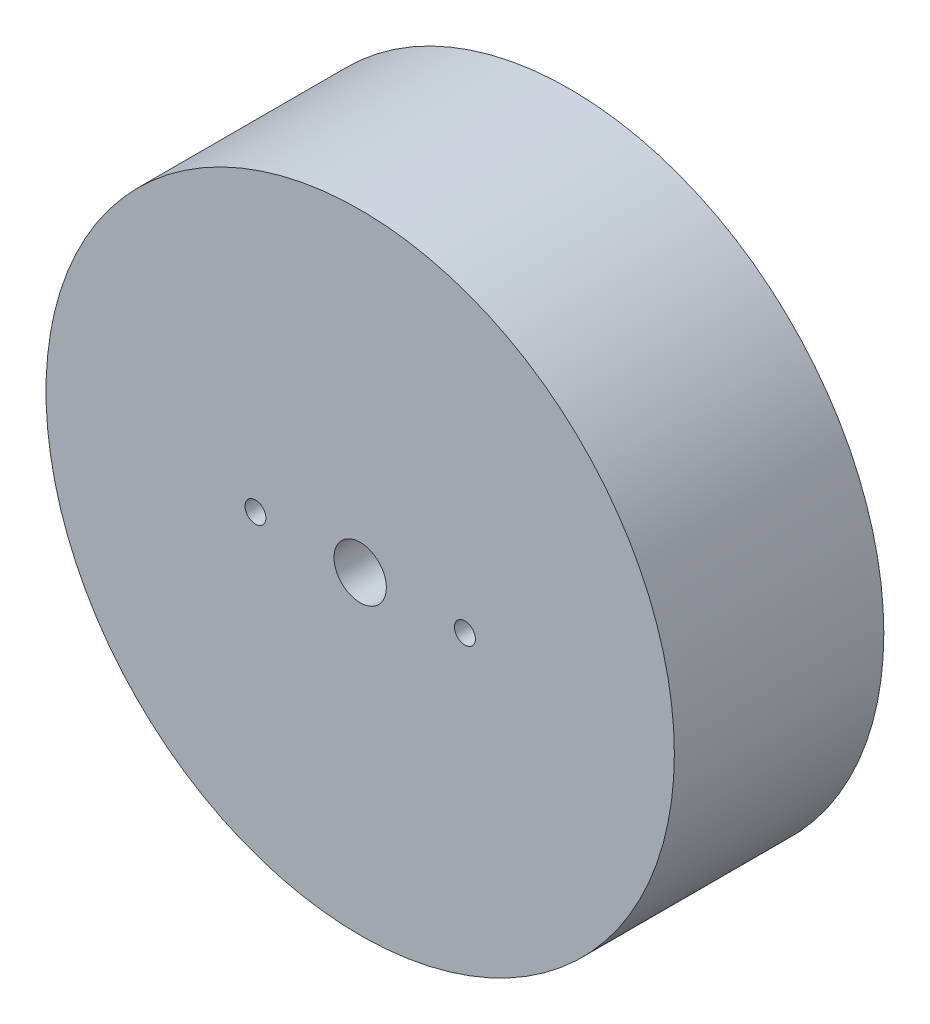
from build123d import *

# Parameters (mm, degrees)
SKETCH1_R           = 30
SKETCH1_R_2         = 1
BOSS_EXTRUDE1_DEPTH = 20
SKETCH3_R           = 2.5
CUT_EXTRUDE1_DEPTH  = 21


with BuildPart() as part:
    # Sketch1 → Boss-Extrude1 (new body)
    with BuildSketch(Plane.XY):
        Circle(SKETCH1_R)
        with Locations((10, 0)):
            Circle(SKETCH1_R_2, mode=Mode.SUBTRACT)
        with Locations((-10, 0)):
            Circle(SKETCH1_R_2, mode=Mode.SUBTRACT)
    extrude(amount=BOSS_EXTRUDE1_DEPTH)

    # Sketch3 → Cut-Extrude1 (cut, through all)
    with BuildSketch(Plane.XY.offset(20)):
        Circle(SKETCH3_R)
    extrude(amount=-CUT_EXTRUDE1_DEPTH, mode=Mode.SUBTRACT)


solid = part.part
